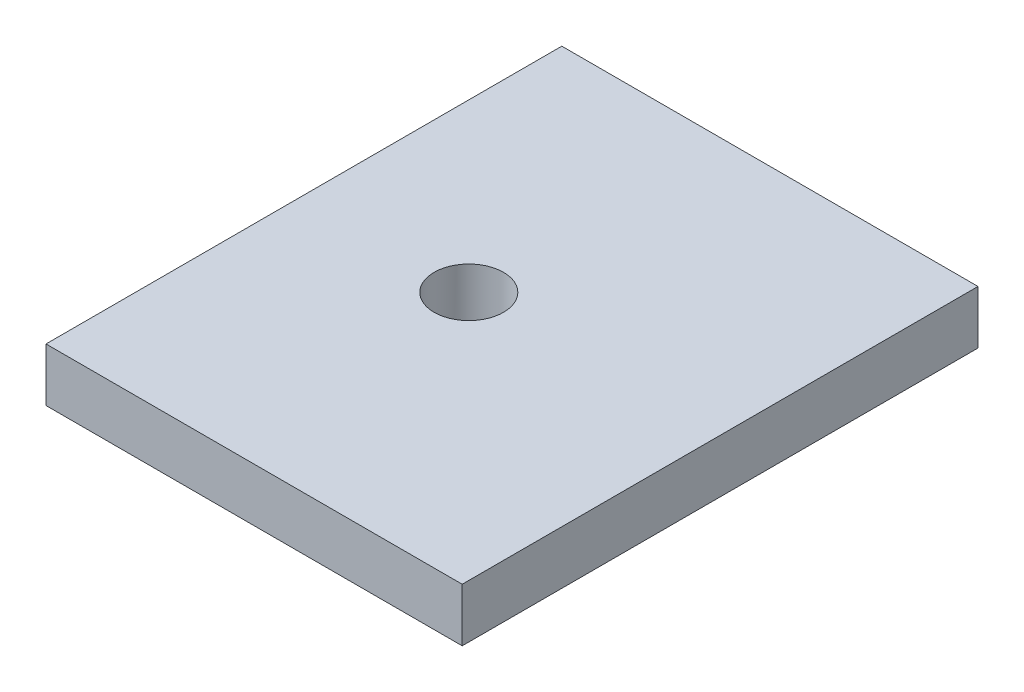
from build123d import *

# Parameters (mm, degrees)
BOSS_EXTRUDE1_DEPTH   = 3
BOSS_EXTRUDE1_2_DEPTH = 3
SKETCH1_W             = 23.4
SKETCH1_H             = 29
SKETCH1_R             = 1
BOSS_EXTRUDE1_3_DEPTH = 3
SKETCH5_R             = 1.44
CUT_EXTRUDE3_DEPTH    = 10
CUT_EXTRUDE4_DEPTH    = 10
SKETCH8_R             = 1
CUT_EXTRUDE5_DEPTH    = 10
SKETCH9_R             = 3.026992654
BOSS_EXTRUDE3_DEPTH   = 3
SKETCH10_R            = 1.95
CUT_EXTRUDE6_DEPTH    = 10
SKETCH11_W            = 23.4
SKETCH11_H            = 29
SKETCH11_R            = 1.95
BOSS_EXTRUDE4_DEPTH   = 3


with BuildPart() as part:
    # Sketch1 → Boss-Extrude1 (new body)
    with BuildSketch(Plane(origin=(0, 0, 0), x_dir=(1, 0, 0), z_dir=(0, 1, 0))):
        with BuildLine():
            add(Edge.make_bspline(
                [(19.180993887, -14.242526212), (19.80083761, -12.341053413), (17.899318471, -11.721194585), (17.279474749, -13.622667384), (16.659631026, -15.524140184), (18.561150164, -16.143999012), (19.180993887, -14.242526212)],
                knots=[0, 0, 0, 0, 0.5, 0.5, 0.5, 1, 1, 1, 1], degree=3, weights=[1, 0.333333333, 0.333333333, 1, 0.333333333, 0.333333333, 1]))
        make_face()
    extrude(amount=BOSS_EXTRUDE1_DEPTH)


with BuildPart() as body_2:
    # Sketch1 → Boss-Extrude1 2 (new body)
    with BuildSketch(Plane(origin=(0, 0, 0), x_dir=(1, 0, 0), z_dir=(0, 1, 0))):
        with BuildLine():
            add(Edge.make_bspline(
                [(22.488505608, -4.096188772), (23.108349331, -2.194715972), (21.206830193, -1.574857144), (20.58698647, -3.476329943), (19.967142747, -5.377802743), (21.868661885, -5.997661571), (22.488505608, -4.096188772)],
                knots=[0, 0, 0, 0, 0.5, 0.5, 0.5, 1, 1, 1, 1], degree=3, weights=[1, 0.333333333, 0.333333333, 1, 0.333333333, 0.333333333, 1]))
        make_face()
    extrude(amount=BOSS_EXTRUDE1_2_DEPTH)


with BuildPart() as body_3:
    # Sketch1 → Boss-Extrude1 3 (new body)
    with BuildSketch(Plane(origin=(0, 0, 0), x_dir=(1, 0, 0), z_dir=(0, 1, 0))):
        Rectangle(SKETCH1_W, SKETCH1_H)
        with Locations(Location((9, 8.9, 0), (0, 0, 270))):
            Circle(SKETCH1_R, mode=Mode.SUBTRACT)
        with Locations(Location((9, -8.5, 0), (0, 0, 90))):
            Circle(SKETCH1_R, mode=Mode.SUBTRACT)
        with Locations(Location((-9, -8.5, 0), (0, 0, 90))):
            Circle(SKETCH1_R, mode=Mode.SUBTRACT)
        with Locations(Location((1.7, -8.5, 0), (0, 0, 90))):
            Circle(SKETCH1_R, mode=Mode.SUBTRACT)
    extrude(amount=BOSS_EXTRUDE1_3_DEPTH)

    # Sketch5 → Cut-Extrude3 (cut)
    with BuildSketch(Plane.XZ):
        with Locations(Location((-2.145634177, 3.61037734, 0), (0, 0, 270))):
            Circle(SKETCH5_R)
    extrude(amount=-CUT_EXTRUDE3_DEPTH, mode=Mode.SUBTRACT)

    # Sketch8 → Cut-Extrude5 (cut)
    with BuildSketch(Plane(origin=(0, 3, 0), x_dir=(1, 0, 0), z_dir=(0, 1, 0))):
        with Locations(Location((1.7, 8.9, 0), (0, 0, 270))):
            Circle(SKETCH8_R)
        with Locations(Location((-9, 8.9, 0), (0, 0, 270))):
            Circle(SKETCH8_R)
    extrude(amount=-CUT_EXTRUDE5_DEPTH, mode=Mode.SUBTRACT)

    # Sketch9 → Boss-Extrude3 (add)
    with BuildSketch(Plane(origin=(0, 3, 0), x_dir=(1, 0, 0), z_dir=(0, 1, 0))):
        with Locations((-2.145634177, -3.61037734)):
            Circle(SKETCH9_R)
    extrude(amount=-BOSS_EXTRUDE3_DEPTH)

    # Sketch10 → Cut-Extrude6 (cut)
    with BuildSketch(Plane(origin=(0, 3, 0), x_dir=(1, 0, 0), z_dir=(0, 1, 0))):
        with Locations(Location((-2.328177417, -0.1, 0), (0, 0, 270))):
            Circle(SKETCH10_R)
    extrude(amount=-CUT_EXTRUDE6_DEPTH, mode=Mode.SUBTRACT)

    # Sketch11 → Boss-Extrude4 (add)
    with BuildSketch(Plane(origin=(0, 3, 0), x_dir=(1, 0, 0), z_dir=(0, 1, 0))):
        Rectangle(SKETCH11_W, SKETCH11_H)
        with Locations(Location((-2.328177417, -0.1, 0), (0, 0, 270))):
            Circle(SKETCH11_R, mode=Mode.SUBTRACT)
    extrude(amount=-BOSS_EXTRUDE4_DEPTH)


with BuildPart() as cut_extrude4_tool:
    # Sketch7 → Cut-Extrude4 (new body)
    with BuildSketch(Plane(origin=(0, 3, 0), x_dir=(1, 0, 0), z_dir=(0, 1, 0))):
        with BuildLine():
            add(Edge.make_bspline(
                [(19.180993887, -14.242526212), (19.80083761, -12.341053413), (17.899318471, -11.721194585), (17.279474749, -13.622667384), (16.659631026, -15.524140184), (18.561150164, -16.143999012), (19.180993887, -14.242526212)],
                knots=[0, 0, 0, 0, 0.5, 0.5, 0.5, 1, 1, 1, 1], degree=3, weights=[1, 0.333333333, 0.333333333, 1, 0.333333333, 0.333333333, 1]))
        make_face()
        with BuildLine():
            add(Edge.make_bspline(
                [(22.488505608, -4.096188772), (23.108349331, -2.194715972), (21.206830193, -1.574857144), (20.58698647, -3.476329943), (19.967142747, -5.377802743), (21.868661885, -5.997661571), (22.488505608, -4.096188772)],
                knots=[0, 0, 0, 0, 0.5, 0.5, 0.5, 1, 1, 1, 1], degree=3, weights=[1, 0.333333333, 0.333333333, 1, 0.333333333, 0.333333333, 1]))
        make_face()
    extrude(amount=-CUT_EXTRUDE4_DEPTH)


with BuildPart() as part_1:
    add(part.part)

    # Cut-Extrude4: cut by cut_extrude4_tool
    add(cut_extrude4_tool.part, mode=Mode.SUBTRACT)


with BuildPart() as body_2_1:
    add(body_2.part)

    # Cut-Extrude4: cut by cut_extrude4_tool
    add(cut_extrude4_tool.part, mode=Mode.SUBTRACT)


solid = body_3.part
